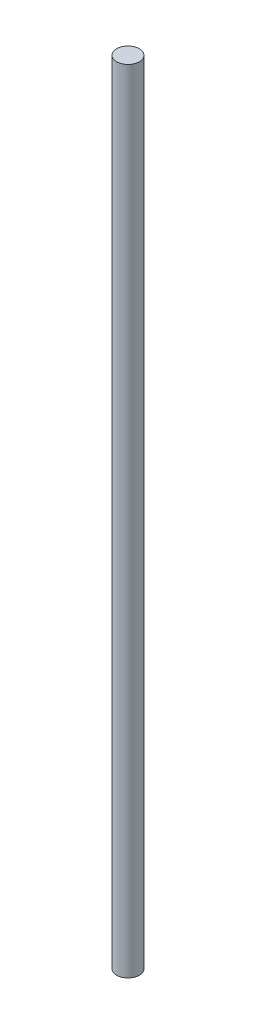
from build123d import *

# Parameters (mm, degrees)
ESQUISSE1_R        = 3
BOSS_EXTRU_1_DEPTH = 210


with BuildPart() as part:
    # Esquisse1 → Boss.-Extru.1 (new body)
    with BuildSketch(Plane(origin=(0, 0, 0), x_dir=(1, 0, 0), z_dir=(0, 1, 0))):
        Circle(ESQUISSE1_R)
    extrude(amount=BOSS_EXTRU_1_DEPTH)


solid = part.part
